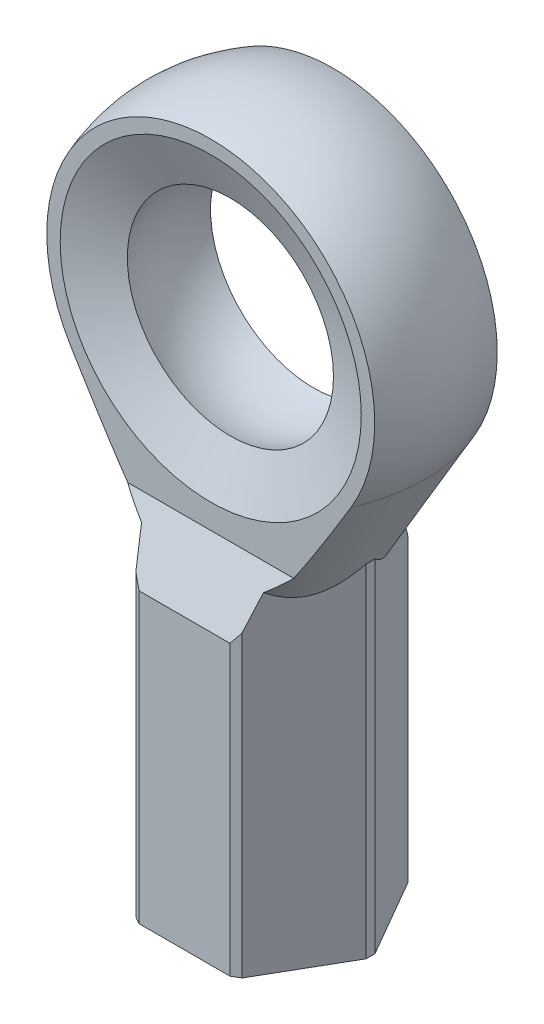
from build123d import *

# Parameters (mm, degrees)
BOSS_EXTRUDE1_DEPTH     = 30
CUT_EXTRUDE1_DEPTH      = 11
CUT_EXTRUDE1_DEPTH_BACK = 11


with BuildPart() as part:
    # Sketch1 → Boss-Extrude1 (new body)
    with BuildSketch(Plane(origin=(0, 0, 0), x_dir=(1, 0, 0), z_dir=(0, 1, 0))):
        with BuildLine():
            Line((-5.624045, -0.258867), (-3.036209, -4.741133))
            ThreePointArc((-3.036209, -4.741133), (-2.815, -4.875723), (-2.587837, -5))
            Line((-2.587837, -5), (2.587837, -5))
            ThreePointArc((2.587837, -5), (2.815, -4.875723), (3.036209, -4.741133))
            Line((3.036209, -4.741133), (5.624045, -0.258867))
            ThreePointArc((5.624045, -0.258867), (5.63, 0), (5.624045, 0.258867))
            Line((5.624045, 0.258867), (3.036209, 4.741133))
            ThreePointArc((3.036209, 4.741133), (2.815, 4.875723), (2.587837, 5))
            Line((2.587837, 5), (-2.587837, 5))
            ThreePointArc((-2.587837, 5), (-2.815, 4.875723), (-3.036209, 4.741133))
            Line((-3.036209, 4.741133), (-5.624045, 0.258867))
            ThreePointArc((-5.624045, 0.258867), (-5.63, 0), (-5.624045, -0.258867))
        make_face()
    extrude(amount=BOSS_EXTRUDE1_DEPTH)

    # Sketch2 → Revolve1 (revolve)
    with BuildSketch(Plane.XY):
        with BuildLine():
            Line((8.746197, 25.151904), (0, 9.373347))
            Line((0, 9.373347), (0, 40))
            ThreePointArc((0, 40), (8.616292, 35.075384), (8.746197, 25.151904))
        make_face()
    revolve(axis=Axis((0, 9.373347, 0), (0, 1, 0)))

    # Sketch3 → Cut-Extrude1 (cut, two sides: drawn at the far end of the back side and taken through both)
    with BuildSketch(Plane(origin=(0, 0, 0), x_dir=(0, 0, -1), z_dir=(1, 0, 0)).offset(-CUT_EXTRUDE1_DEPTH_BACK)):
        Polygon((-11, 10), (-7.746665, 10), (-3.5, 20.004517), (-3.5, 40), (3.5, 40), (3.5, 20.004517), (7.746665, 10), (11, 10), (11, 50), (-11, 50), align=None)
    extrude(amount=CUT_EXTRUDE1_DEPTH + CUT_EXTRUDE1_DEPTH_BACK, mode=Mode.SUBTRACT)

    # Sketch4 → Cut-Revolve1 (revolve, cut)
    with BuildSketch(Plane.XY):
        Polygon((0, 14.919416), (2.4585, 13.5), (2.4585, 0.5415), (3, 0), (0, 0), align=None)
    revolve(axis=Axis((0, 0, 0), (0, 1, 0)), mode=Mode.SUBTRACT)

    # Sketch5 → Cut-Revolve2 (revolve, cut)
    with BuildSketch(Plane(origin=(0, 0, 0), x_dir=(0, 0, -1), z_dir=(1, 0, 0))):
        with BuildLine():
            Line((-4.5, 30), (-4.5, 38.6))
            Line((-4.5, 38.6), (-3.5, 38.6))
            Line((-3.5, 38.6), (-2.376818, 35.888398))
            ThreePointArc((-2.376818, 35.888398), (0, 36.35), (2.376818, 35.888398))
            Line((2.376818, 35.888398), (3.5, 38.6))
            Line((3.5, 38.6), (4.5, 38.6))
            Line((4.5, 38.6), (4.5, 30))
            Line((4.5, 30), (-4.5, 30))
        make_face()
    revolve(axis=Axis((0, 30, -4.5), (0, 0, 1)), mode=Mode.SUBTRACT)


solid = part.part
